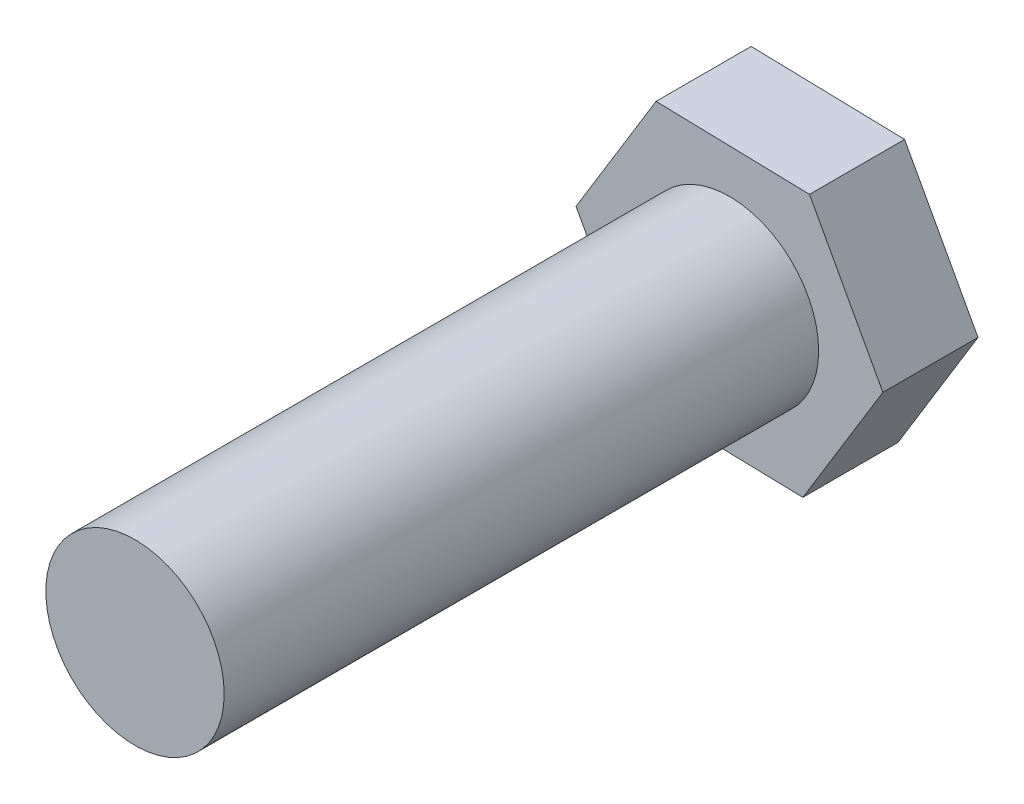
from build123d import *

# Parameters (mm, degrees)
EXTRUDE1_DEPTH    = 36.83
SKETCH2_OUTSIDE_W = 26.952
SKETCH2_OUTSIDE_H = 24.962
SKETCH2_OUTSIDE_R = 4.7625
EXTRUDE2_DEPTH    = 31.75


with BuildPart() as part:
    # Sketch1 → Extrude1 (new body)
    with BuildSketch(Plane.XY):
        Polygon((4.274924982, 6.994647743), (-3.920080145, 7.199517506), (-8.195005127, 0.204869763), (-4.274924982, -6.994647743), (3.920080145, -7.199517506), (8.195005127, -0.204869763), align=None)
    extrude(amount=EXTRUDE1_DEPTH)

    # Sketch2 outside → Extrude2 (cut)
    with BuildSketch(Plane.XY.offset(36.83)):
        Rectangle(SKETCH2_OUTSIDE_W, SKETCH2_OUTSIDE_H)
        Circle(SKETCH2_OUTSIDE_R, mode=Mode.SUBTRACT)
    extrude(amount=-EXTRUDE2_DEPTH, mode=Mode.SUBTRACT)


solid = part.part
